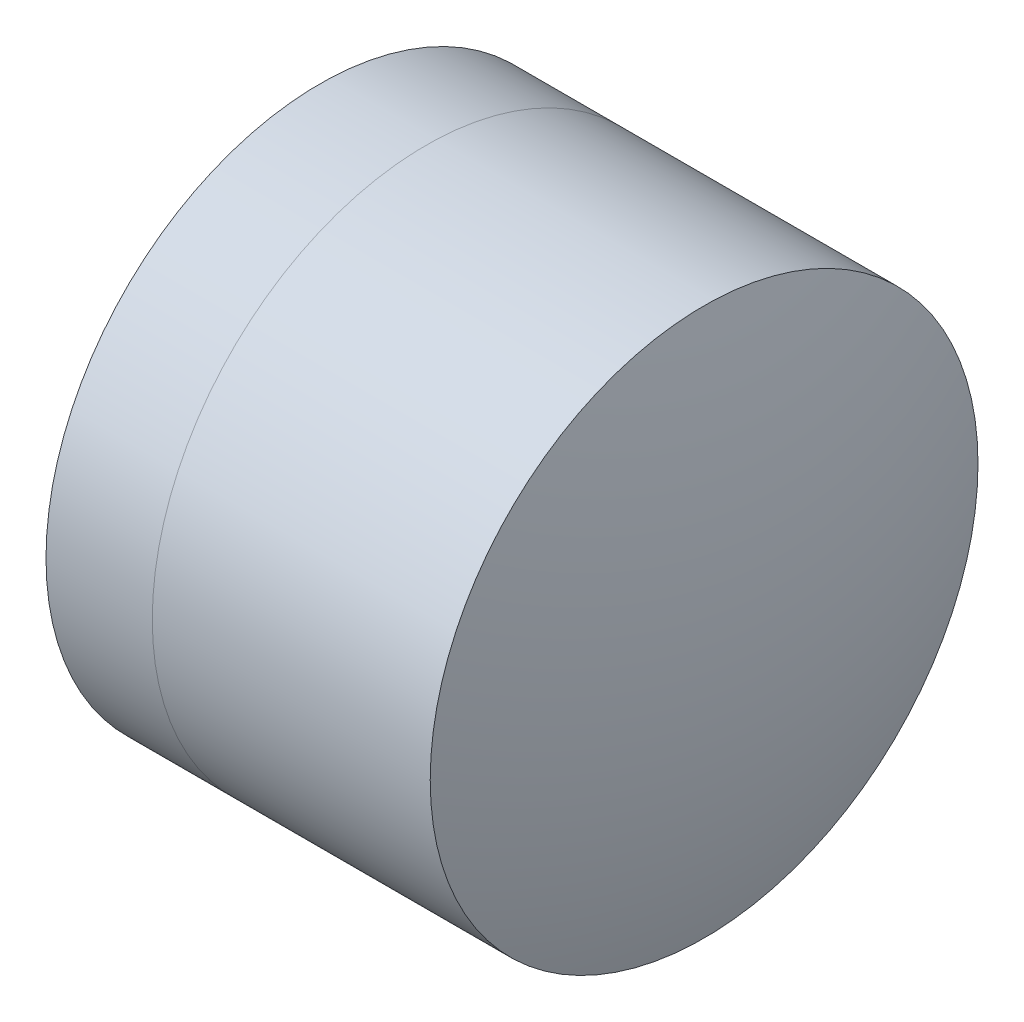
from build123d import *


with BuildPart() as part:
    # 草图1 one side → 旋转1 (revolve)
    with BuildSketch(Plane(origin=(0, 0, 0), x_dir=(1, 0, 0), z_dir=(0, 1, 0)), mode=Mode.PRIVATE) as revolve_1_sk:
        with BuildLine():
            ThreePointArc((2.568094164, 3.15), (1.995242871, 1.621075309), (1.80060434, 0))
            Line((1.80060434, 0), (5.24060434, 0))
            ThreePointArc((5.24060434, 0), (4.860616931, 1.733916136), (3.790307588, 3.15))
            Line((3.790307588, 3.15), (2.568094164, 3.15))
        make_face()
    revolve(revolve_1_sk.sketch.rotate(Axis((-0.816062176, 0, 0), (1, 0, 0)), 180), axis=Axis((-0.816062176, 0, 0), (1, 0, 0)))  # turned: the seam where the file's is


with BuildPart() as body_2:
    # 草图2 one side → 旋转3 (revolve)
    with BuildSketch(Plane(origin=(0, 0, 0), x_dir=(1, 0, 0), z_dir=(0, 1, 0)), mode=Mode.PRIVATE) as revolve_3_sk:
        with BuildLine():
            Line((6.986827555, 3.15), (3.790307588, 3.15))
            ThreePointArc((3.790307588, 3.15), (4.860616931, 1.733916136), (5.24060434, 0))
            Line((5.24060434, 0), (7.49060434, 0))
            ThreePointArc((7.49060434, 0), (7.363864952, 1.595014972), (6.986827555, 3.15))
        make_face()
    revolve(revolve_3_sk.sketch.rotate(Axis((-0.551919993, 0, 0), (1, 0, 0)), 180), axis=Axis((-0.551919993, 0, 0), (1, 0, 0)))  # turned: the seam where the file's is


solid = Compound([part.part, body_2.part])
